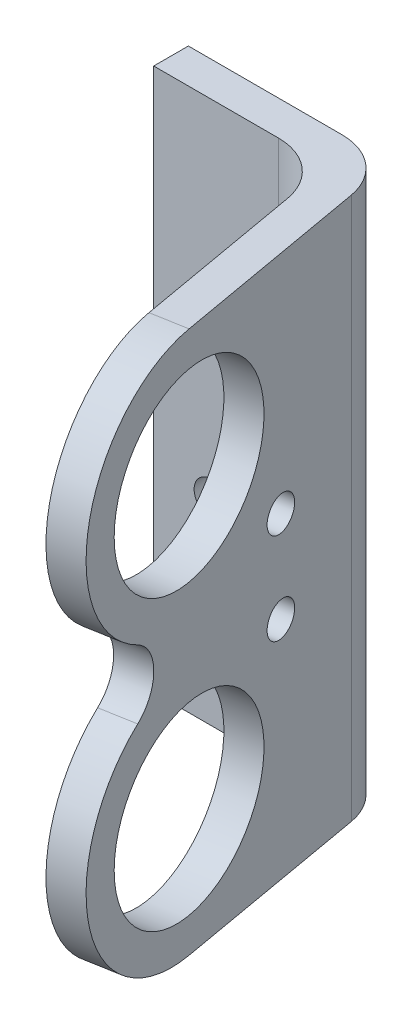
from build123d import *

# Parameters (mm, degrees)
BOSS_EXTRUDE1_DEPTH = 47
SKETCH2_R           = 1.5
CUT_EXTRUDE1_DEPTH  = 4
SKETCH3_R           = 8
CUT_EXTRUDE2_DEPTH  = 9.560785614
SKETCH4_R           = 1.47
CUT_EXTRUDE3_DEPTH  = 9.560785614


with BuildPart() as part:
    # Sketch1 → Boss-Extrude1 (new body)
    with BuildSketch(Plane(origin=(0, 0, 0), x_dir=(1, 0, 0), z_dir=(0, 1, 0))):
        with BuildLine():
            Line((-2.32059976, 10.913457617), (11.001200978, 10.913457617))
            ThreePointArc((11.001200978, 10.913457617), (14.215139026, 9.743679833), (15.925239743, 6.781698506))
            Line((15.925239743, 6.781698506), (20.843268829, -21.10983044))
            Line((20.843268829, -21.10983044), (17.88884557, -21.630774973))
            Line((17.88884557, -21.630774973), (13.407940849, 3.781698506))
            ThreePointArc((13.407940849, 3.781698506), (11.697840132, 6.743679833), (8.483902084, 7.913457617))
            Line((8.483902084, 7.913457617), (-2.32059976, 7.913457617))
            Line((-2.32059976, 7.913457617), (-2.32059976, 10.913457617))
        make_face()
    extrude(amount=BOSS_EXTRUDE1_DEPTH)

    # Sketch2 → Cut-Extrude1 (cut, through all)
    with BuildSketch(Plane.XY.offset(-7.913457617)):
        with Locations((2.67940024, 30)):
            Circle(SKETCH2_R)
        with Locations((2.67940024, 17)):
            Circle(SKETCH2_R)
    extrude(amount=-CUT_EXTRUDE1_DEPTH, mode=Mode.SUBTRACT)

    # Sketch3 → Cut-Extrude2 (cut, through all)
    with BuildSketch(Plane(origin=(13.650350495, 0, -2.406925088), x_dir=(0.173648178, 0, 0.984807753), z_dir=(-0.984807753, 0, 0.173648178))):
        with BuildLine():
            Line((24.408520331, 47), (13.408520331, 47))
            ThreePointArc((13.408520331, 47), (21.186694924, 43.778174593), (24.408520331, 36))
            Line((24.408520331, 36), (24.408520331, 47))
        make_face()
        with BuildLine():
            Line((24.408520331, 0), (24.408520331, 11))
            ThreePointArc((24.408520331, 11), (21.186694924, 3.221825407), (13.408520331, 0))
            Line((13.408520331, 0), (24.408520331, 0))
        make_face()
        with Locations((13.408520331, 11)):
            Circle(SKETCH3_R)
        with Locations((13.408520331, 36)):
            Circle(SKETCH3_R)
        with BuildLine():
            Line((24.408520331, 11), (24.408520331, 36))
            ThreePointArc((24.408520331, 36), (22.930853605, 30.493170692), (18.894853235, 26.465842918))
            ThreePointArc((18.894853235, 26.465842918), (17.17968635, 23.5), (18.894853235, 20.534157082))
            ThreePointArc((18.894853235, 20.534157082), (22.930853605, 16.506829308), (24.408520331, 11))
        make_face()
    extrude(amount=-CUT_EXTRUDE2_DEPTH, mode=Mode.SUBTRACT)

    # Sketch4 → Cut-Extrude3 (cut, through all)
    with BuildSketch(Plane(origin=(13.650350495, 0, -2.406925088), x_dir=(0.173648178, 0, 0.984807753), z_dir=(-0.984807753, 0, 0.173648178))):
        with Locations((3.604018487, 27.463505193)):
            Circle(SKETCH4_R)
        with Locations((3.604018487, 19.536494807)):
            Circle(SKETCH4_R)
    extrude(amount=-CUT_EXTRUDE3_DEPTH, mode=Mode.SUBTRACT)


solid = part.part
